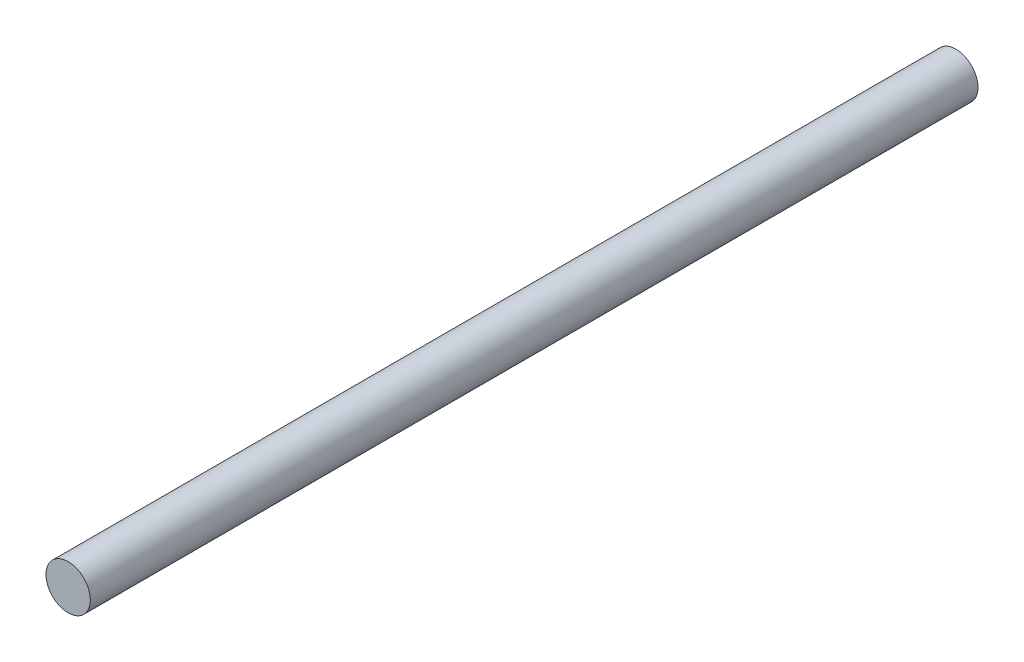
from build123d import *

# Parameters (mm, degrees)
SKETCH1_R           = 10
SHAFT_EXTRUDE_DEPTH = 400


with BuildPart() as part:
    # Sketch1 → Shaft Extrude (new body)
    with BuildSketch(Plane.XY):
        Circle(SKETCH1_R)
    extrude(amount=SHAFT_EXTRUDE_DEPTH)


solid = part.part
